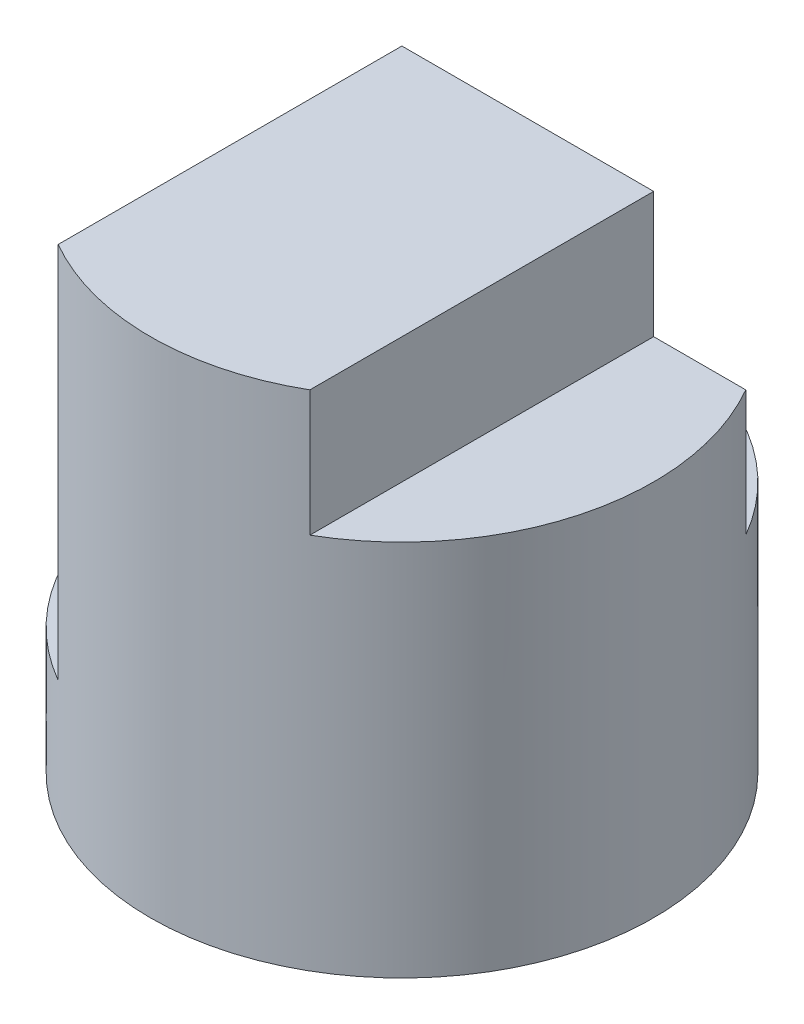
from build123d import *

# Parameters (mm, degrees)
SKETCH1_R               = 2
BOSS_EXTRUDE1_DEPTH     = 4
SKETCH2_W               = 1
SKETCH2_H               = 1
CUT_EXTRUDE1_DEPTH      = 2
CUT_EXTRUDE2_DEPTH      = 2
SKETCH4_W               = 0.999117212
SKETCH4_H               = 1
CUT_EXTRUDE3_DEPTH      = 2
CUT_EXTRUDE3_DEPTH_BACK = 1


with BuildPart() as part:
    # Sketch1 → Boss-Extrude1 (new body)
    with BuildSketch(Plane(origin=(0, 0, 0), x_dir=(1, 0, 0), z_dir=(0, 1, 0))):
        Circle(SKETCH1_R)
    extrude(amount=BOSS_EXTRUDE1_DEPTH)

    # Sketch2 → Cut-Extrude1 (cut, symmetric)
    with BuildSketch(Plane.XY):
        Polygon((-1.000882788, 3), (-1.000882788, 4), (-2, 4), (-2, 2), (-1.000882788, 2), align=None)
        with Locations((1.5, 3.5)):
            Rectangle(SKETCH2_W, SKETCH2_H)
    extrude(amount=CUT_EXTRUDE1_DEPTH, both=True, mode=Mode.SUBTRACT)

    # Sketch3 → Cut-Extrude2 (cut)
    with BuildSketch(Plane(origin=(0, 4, 0), x_dir=(1, 0, 0), z_dir=(0, 1, 0))):
        with BuildLine():
            Line((-1.732050808, 1), (1.732050808, 1))
            ThreePointArc((1.732050808, 1), (0, 2), (-1.732050808, 1))
        make_face()
    extrude(amount=-CUT_EXTRUDE2_DEPTH, mode=Mode.SUBTRACT)

    # Sketch4 → Cut-Extrude3 (cut, two sides)
    with BuildSketch(Plane.XY) as cut_extrude3_sk:
        with Locations((-1.500441394, 1.5)):
            Rectangle(SKETCH4_W, SKETCH4_H)
    extrude(amount=CUT_EXTRUDE3_DEPTH, mode=Mode.SUBTRACT)
    extrude(cut_extrude3_sk.sketch, amount=-CUT_EXTRUDE3_DEPTH_BACK, mode=Mode.SUBTRACT)


solid = part.part
